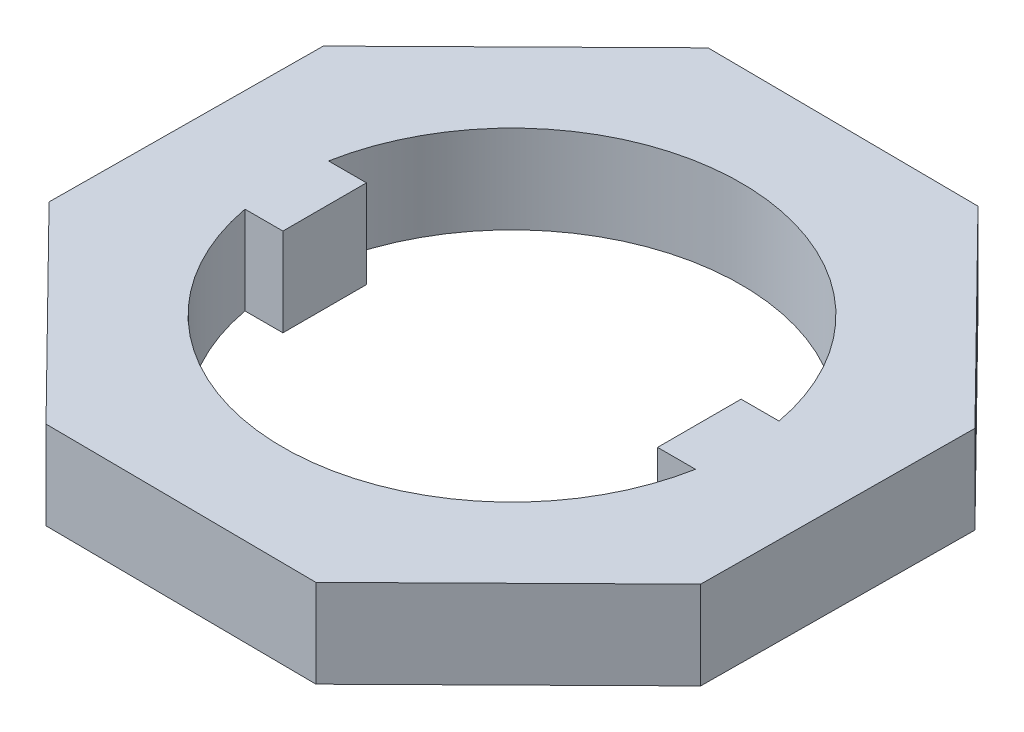
from build123d import *

# Parameters (mm, degrees)
BOSS_EXTRUDE1_DEPTH = 1.9


with BuildPart() as part:
    # Sketch1 → Boss-Extrude1 (new body)
    with BuildSketch(Plane(origin=(0, 0, 0), x_dir=(1, 0, 0), z_dir=(0, 1, 0))):
        Polygon((2.875222959, -7.101510951), (7.054616202, -2.988436898), (7.101510951, 2.875222959), (2.988436898, 7.054616202), (-2.875222959, 7.101510951), (-7.054616202, 2.988436898), (-7.101510951, -2.875222959), (-2.988436898, -7.054616202), align=None)
        with BuildLine():
            Line((-4.854615023, 0.9), (-4.037336024, 0.9))
            Line((-4.037336024, 0.9), (-4.037336024, -0.9))
            Line((-4.037336024, -0.9), (-4.854615023, -0.9))
            ThreePointArc((-4.854615023, -0.9), (0, -4.937336024), (4.854615023, -0.9))
            Line((4.854615023, -0.9), (4.037336024, -0.9))
            Line((4.037336024, -0.9), (4.037336024, 0.9))
            Line((4.037336024, 0.9), (4.854615023, 0.9))
            ThreePointArc((4.854615023, 0.9), (0, 4.937336024), (-4.854615023, 0.9))
        make_face(mode=Mode.SUBTRACT)
    extrude(amount=BOSS_EXTRUDE1_DEPTH)


solid = part.part
